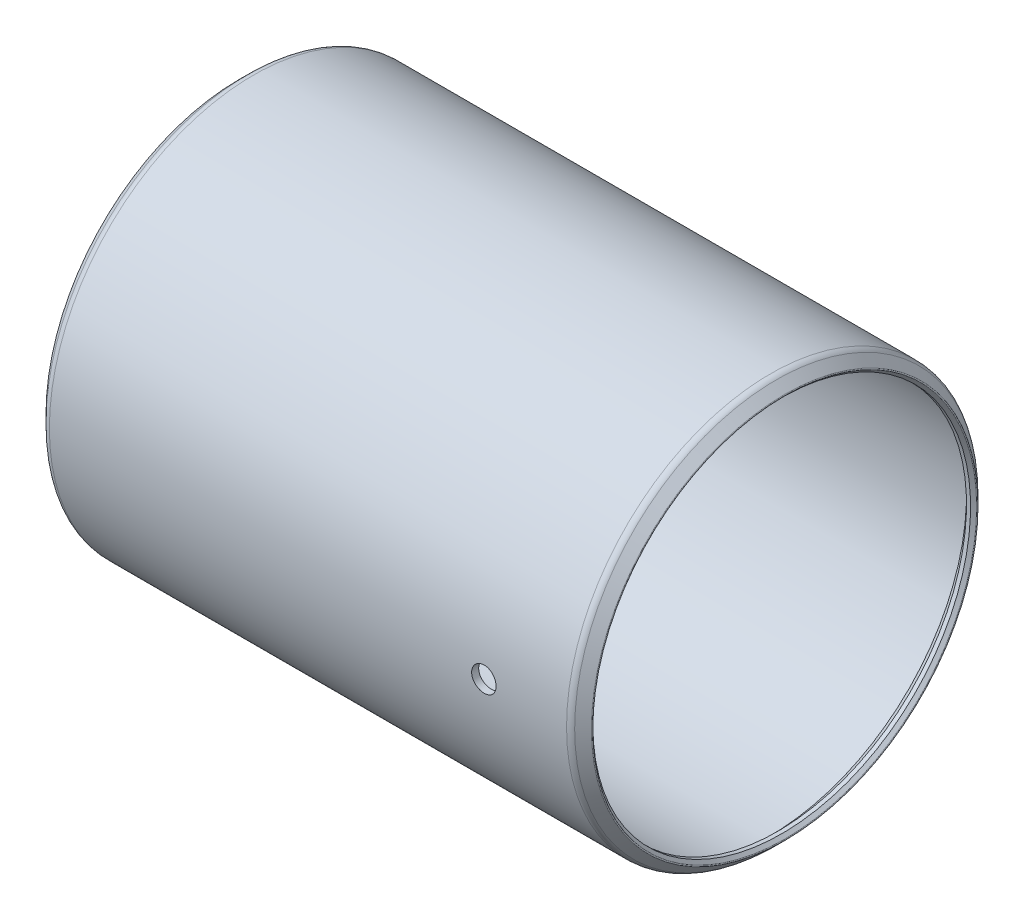
from build123d import *

# Parameters (mm, degrees)
SKETCH2_R          = 1.5875
CUT_EXTRUDE1_DEPTH = 26.48585


with BuildPart() as part:
    # Sketch1 → Revolve1 (revolve)
    with BuildSketch(Plane.XY):
        with BuildLine():
            Line((-0.919083697, 24.909383697), (-0.52705, 24.51735))
            Line((-0.52705, 24.51735), (0, 24.51735))
            Line((0, 24.51735), (1.0541, 25.57145))
            Line((1.0541, 25.57145), (67.9069, 25.57145))
            Line((67.9069, 25.57145), (68.961, 24.51735))
            Line((68.961, 24.51735), (69.48805, 24.51735))
            Line((69.48805, 24.51735), (69.880083697, 24.909383697))
            ThreePointArc((69.880083697, 24.909383697), (69.917281136, 24.999186258), (69.880083697, 25.088988819))
            Line((69.880083697, 25.088988819), (68.791961258, 26.177111258))
            ThreePointArc((68.791961258, 26.177111258), (68.449986606, 26.405611415), (68.0466, 26.48585))
            Line((68.0466, 26.48585), (0.9144, 26.48585))
            ThreePointArc((0.9144, 26.48585), (0.511013394, 26.405611415), (0.169038742, 26.177111258))
            Line((0.169038742, 26.177111258), (-0.919083697, 25.088988819))
            ThreePointArc((-0.919083697, 25.088988819), (-0.956281136, 24.999186258), (-0.919083697, 24.909383697))
        make_face()
    revolve(axis=Axis((68.961, 0, 0), (-1, 0, 0)))

    # Sketch2 → Cut-Extrude1 (cut)
    with BuildSketch(Plane.XY):
        with Locations((57.3151, 0)):
            Circle(SKETCH2_R)
    extrude(amount=CUT_EXTRUDE1_DEPTH, mode=Mode.SUBTRACT)


solid = part.part
